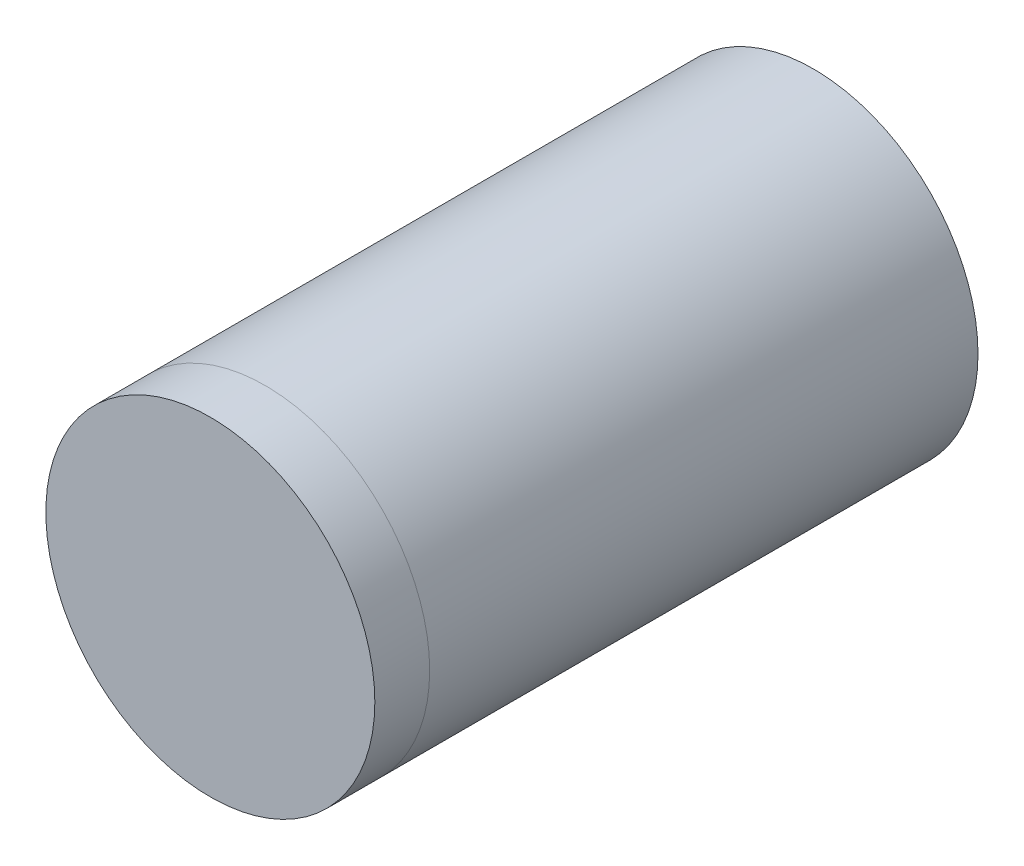
from build123d import *

# Parameters (mm, degrees)
SKETCH1_R           = 9
BOSS_EXTRUDE1_DEPTH = 30
SKETCH2_R           = 9
BOSS_EXTRUDE2_DEPTH = 3


with BuildPart() as part:
    # Sketch1 → Boss-Extrude1 (new body)
    with BuildSketch(Plane.XY):
        Circle(SKETCH1_R)
    extrude(amount=BOSS_EXTRUDE1_DEPTH)


with BuildPart() as body_2:
    # Sketch2 → Boss-Extrude2 (new body)
    with BuildSketch(Plane.XY.offset(30)):
        Circle(SKETCH2_R)
    extrude(amount=BOSS_EXTRUDE2_DEPTH)


solid = Compound([part.part, body_2.part])
